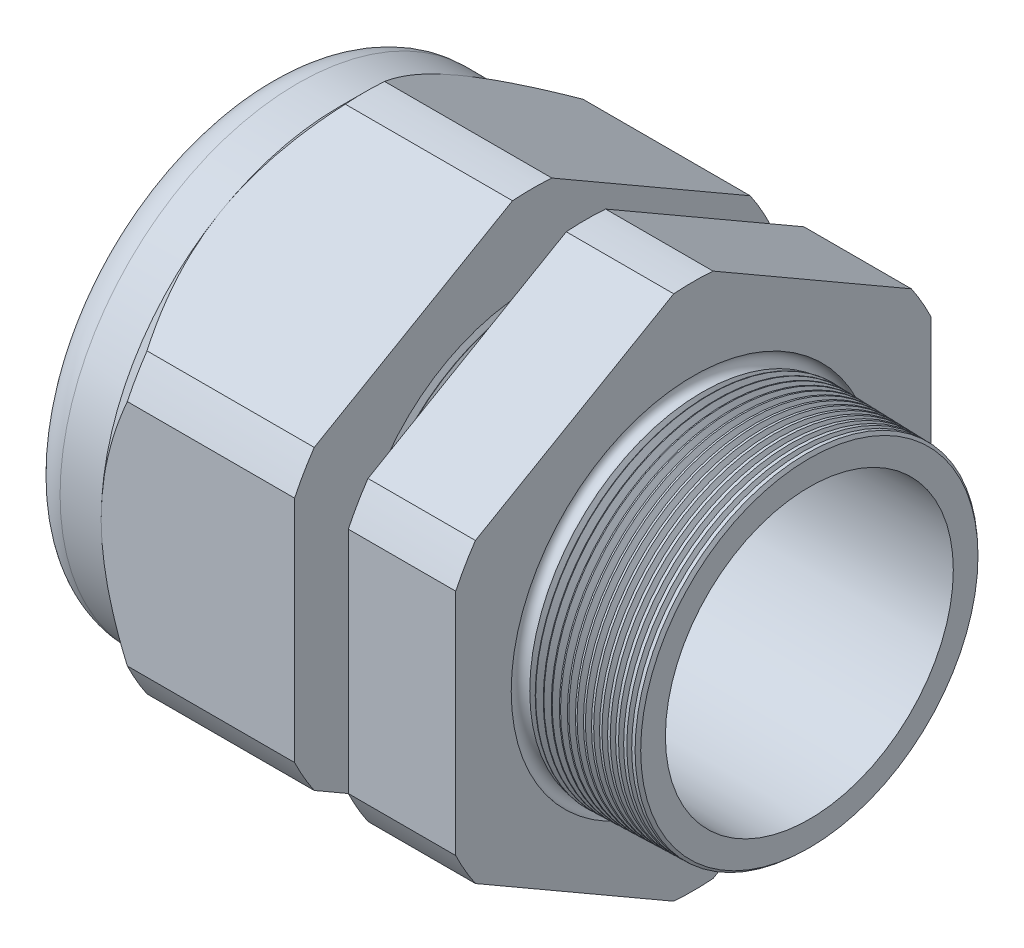
from build123d import *

# Parameters (mm, degrees)
SKETCH12_OUTSIDE_W = 140.582
SKETCH12_OUTSIDE_H = 140.582
CUT_EXTRUDE2_DEPTH = 53.5600168
FILLET4_R          = 3.81
SKETCH19_OUTSIDE_W = 83.088
SKETCH19_OUTSIDE_H = 88.928
SKETCH19_OUTSIDE_R = 26.543
CUT_EXTRUDE3_DEPTH = 3.99796
CUT_EXTRUDE3_DRAFT = -45
CHAMFER1_SIZE      = 0.260919487
CHAMFER1_SIZE2     = 0.254
SKETCH21_R         = 16.002
PLUG_DEPTH         = 12.7
SKETCH22_R         = 15.748
CUT_EXTRUDE4_DEPTH = 0.508
SKETCH27_R         = 7.493
PLUGHOLES_DEPTH    = 61.452
CIRPATTERN1_COUNT  = 2
LPATTERN1_COUNT    = 8
LPATTERN1_PITCH    = 0.762
LPATTERN2_COUNT    = 15
LPATTERN2_PITCH    = 0.889
SKETCH32_R         = 0.889


with BuildPart() as part:
    # Sketch10 → Revolve2 (revolve)
    with BuildSketch(Plane.XY, mode=Mode.PRIVATE) as revolve2_sk:
        Polygon((-55.88, 16.002), (-25.87759112, 16.002), (5.08, 16.080346947), (5.08, 19.128346947), (-7.874, 19.467559375), (-7.874, 53.086), (-19.873976, 53.086), (-19.873976, 19.781789805), (-25.87759112, 19.939), (-25.87759112, 53.086), (-47.4800168, 53.086), (-47.4800168, 26.543), (-55.88, 26.543), align=None)
    revolve(revolve2_sk.sketch.rotate(Axis((0, 0, 0), (-1, 0, 0)), 90), axis=Axis((0, 0, 0), (-1, 0, 0)))  # turned: the seam where the file's is

    # Sketch12 outside → Cut-Extrude2 (cut, through all)
    with BuildSketch(Plane.ZY.offset(47.4800168)):
        Rectangle(SKETCH12_OUTSIDE_W, SKETCH12_OUTSIDE_H)
        with BuildLine():
            Line((-2.19715092, 29.380690715), (-24.34584908, 16.59313387))
            ThreePointArc((-24.34584908, 16.59313387), (-25.515472645, 14.731365), (-26.543, 12.787556845))
            Line((-26.543, 12.787556845), (-26.543, -12.787556845))
            ThreePointArc((-26.543, -12.787556845), (-25.515472645, -14.731365), (-24.34584908, -16.59313387))
            Line((-24.34584908, -16.59313387), (-2.19715092, -29.380690715))
            ThreePointArc((-2.19715092, -29.380690715), (0, -29.46273), (2.19715092, -29.380690715))
            Line((2.19715092, -29.380690715), (24.34584908, -16.59313387))
            ThreePointArc((24.34584908, -16.59313387), (25.515472645, -14.731365), (26.543, -12.787556845))
            Line((26.543, -12.787556845), (26.543, 12.787556845))
            ThreePointArc((26.543, 12.787556845), (25.515472645, 14.731365), (24.34584908, 16.59313387))
            Line((24.34584908, 16.59313387), (2.19715092, 29.380690715))
            ThreePointArc((2.19715092, 29.380690715), (0, 29.46273), (-2.19715092, 29.380690715))
        make_face(mode=Mode.SUBTRACT)
    extrude(amount=-CUT_EXTRUDE2_DEPTH, mode=Mode.SUBTRACT)

    # Fillet4
    fillet4_edges = [part.edges().sort_by_distance(p)[0] for p in [
        (-55.88, 0, 26.543),
    ]]
    fillet(fillet4_edges, radius=FILLET4_R)


with BuildPart() as cut_extrude3_tool:
    # Sketch19 outside → Cut-Extrude3 (with draft: the straight prism first)
    with BuildSketch(Plane.ZY.offset(47.4800168)):
        Rectangle(SKETCH19_OUTSIDE_W, SKETCH19_OUTSIDE_H)
        Circle(SKETCH19_OUTSIDE_R, mode=Mode.SUBTRACT)
    extrude(amount=-CUT_EXTRUDE3_DEPTH)
    # Cut-Extrude3: the draft: its side faces are tilted about the plane it starts from
    cut_extrude3_sides = [cut_extrude3_tool.faces().sort_by_distance(p)[0] for p in [
        (-45.4810368, -44.464, 0),
        (-45.4810368, 0, 41.544),
        (-45.4810368, 44.464, 0),
        (-45.4810368, 0, -41.544),
        (-45.4810368, 0, -26.543),
    ]]
    draft(cut_extrude3_sides, Plane.ZY.offset(47.4800168), CUT_EXTRUDE3_DRAFT)


with BuildPart() as part_1:
    add(part.part)

    # Cut-Extrude3: cut by cut_extrude3_tool
    add(cut_extrude3_tool.part, mode=Mode.SUBTRACT)

    # Chamfer1
    chamfer1_edges = [part_1.edges().sort_by_distance(p)[0] for p in [
        (5.08, 0, 19.128346947),
    ]]
    chamfer1_side = [part_1.faces().sort_by_distance(p)[0] for p in [
        (5.08, 0, 16.621378301),
    ]]
    chamfer(chamfer1_edges, length=CHAMFER1_SIZE, length2=CHAMFER1_SIZE2, reference=chamfer1_side[0])

    # Sketch29 → Cut-Revolve1 (revolve, cut)
    with BuildSketch(Plane.XY, mode=Mode.PRIVATE) as cut_revolve1_sk:
        Polygon((-25.87759112, 19.939), (-25.144607539, 19.919806149), (-25.527721692, 19.294620673), align=None)
    cut_revolve1 = revolve(cut_revolve1_sk.sketch.rotate(Axis((0, 0, 0), (-1, 0, 0)), 90), axis=Axis((0, 0, 0), (-1, 0, 0)), mode=Mode.SUBTRACT)  # turned: the seam where the file's is

    # LPattern1: Cut-Revolve1 ×8
    with Locations(*[(i * LPATTERN1_PITCH, 0, 0) for i in range(1, LPATTERN1_COUNT)]):
        add(cut_revolve1, mode=Mode.SUBTRACT)

    # Sketch30 → Cut-Revolve2 (revolve, cut)
    with BuildSketch(Plane.XY, mode=Mode.PRIVATE) as cut_revolve2_sk:
        Polygon((-7.874, 19.467559375), (-6.994419703, 19.444526754), (-7.454156686, 18.694304183), align=None)
    cut_revolve2 = revolve(cut_revolve2_sk.sketch.rotate(Axis((0, 0, 0), (-1, 0, 0)), 270), axis=Axis((0, 0, 0), (-1, 0, 0)), mode=Mode.SUBTRACT)  # turned: the seam where the file's is

    # LPattern2: Cut-Revolve2 ×15
    with Locations(*[(i * LPATTERN2_PITCH, 0, 0) for i in range(1, LPATTERN2_COUNT)]):
        add(cut_revolve2, mode=Mode.SUBTRACT)

    # Sketch32 → Cut-Revolve3 (revolve, cut)
    with BuildSketch(Plane.XY, mode=Mode.PRIVATE) as cut_revolve3_sk:
        with Locations((-7.747, 19.467559375)):
            Circle(SKETCH32_R)
    revolve(cut_revolve3_sk.sketch.rotate(Axis((0, 0, 0), (-1, 0, 0)), 270), axis=Axis((0, 0, 0), (-1, 0, 0)), mode=Mode.SUBTRACT)  # turned: the seam where the file's is


with BuildPart() as body_2:
    # Sketch21 → plug (new body)
    with BuildSketch(Plane.ZY.offset(55.88)):
        Circle(SKETCH21_R)
    extrude(amount=-PLUG_DEPTH)

    # Sketch22 → Cut-Extrude4 (cut)
    with BuildSketch(Plane.ZY.offset(55.88)):
        Circle(SKETCH22_R)
    extrude(amount=-CUT_EXTRUDE4_DEPTH, mode=Mode.SUBTRACT)

    # Sketch27 → plugholes (cut, through all)
    with BuildSketch(Plane.ZY.offset(55.372)):
        with Locations((-8.225028, 0)):
            Circle(SKETCH27_R)
    plugholes = extrude(amount=-PLUGHOLES_DEPTH, mode=Mode.SUBTRACT)

    # CirPattern1: plugholes ×2 about axis
    cirpattern1_axis = Axis((0, 0, 0), (1, 0, 0))
    for i in range(1, CIRPATTERN1_COUNT):
        add(plugholes.rotate(cirpattern1_axis, i * 360 / CIRPATTERN1_COUNT), mode=Mode.SUBTRACT)


solid = Compound([part_1.part, body_2.part])
